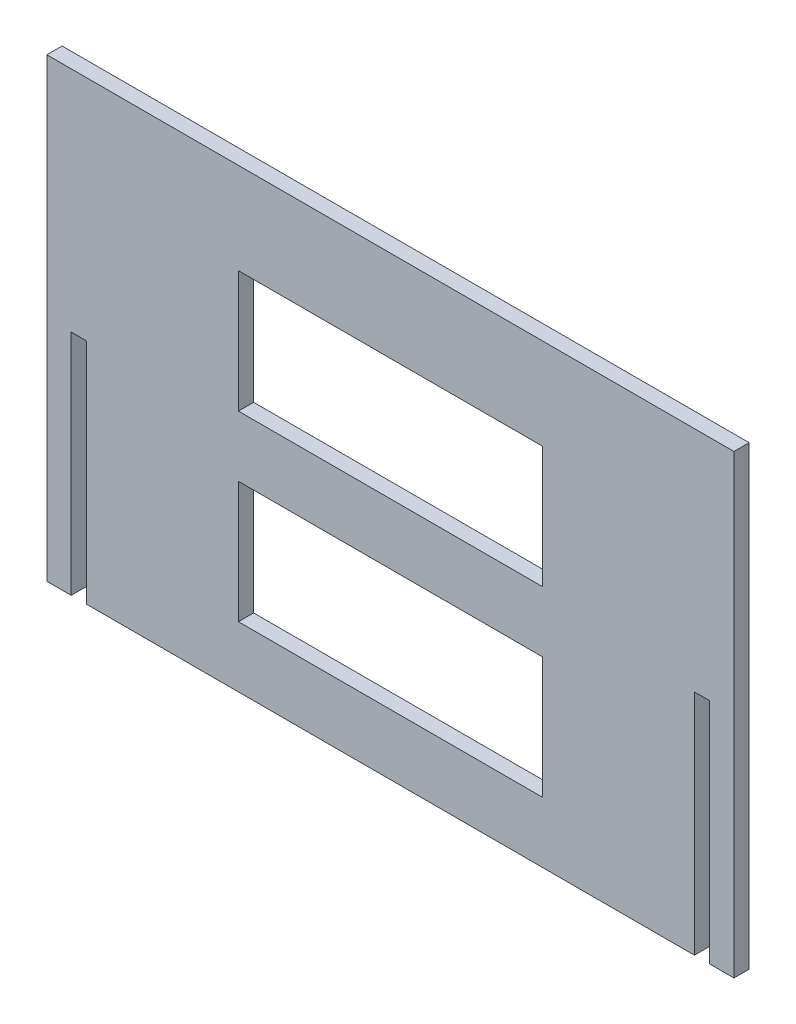
from build123d import *

# Parameters (mm, degrees)
ESQUISSE1_W        = 100
ESQUISSE1_H        = 40
BOSS_EXTRU_1_DEPTH = 5


with BuildPart() as part:
    # Esquisse1 → Boss.-Extru.1 (new body)
    with BuildSketch(Plane.XY):
        Polygon((-8, 0), (0, 0), (0, 75), (5, 75), (5, 0), (205, 0), (205, 75), (210, 75), (210, 0), (218, 0), (218, 150), (-8, 150), align=None)
        with Locations((105, 40)):
            Rectangle(ESQUISSE1_W, ESQUISSE1_H, mode=Mode.SUBTRACT)
        with Locations((105, 100)):
            Rectangle(ESQUISSE1_W, ESQUISSE1_H, mode=Mode.SUBTRACT)
    extrude(amount=BOSS_EXTRU_1_DEPTH)


solid = part.part
